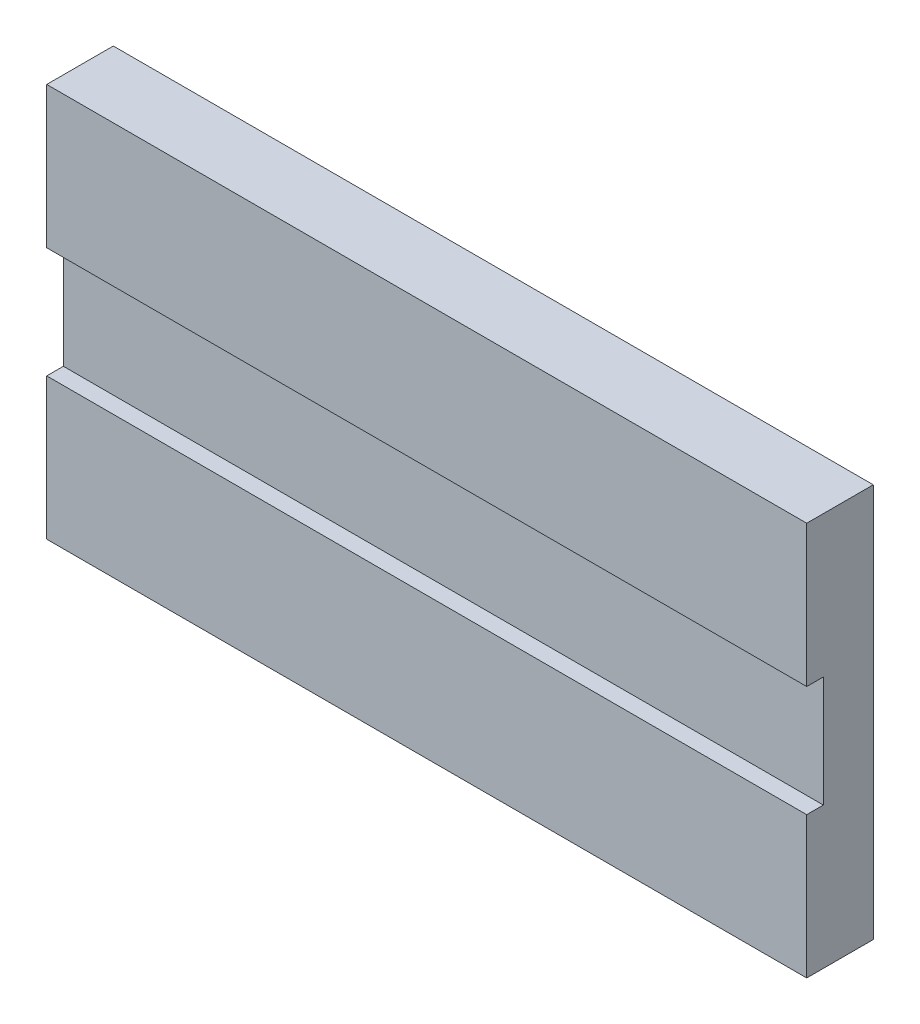
from build123d import *

# Parameters (mm, degrees)
ESQUISSE1_W      = 137
ESQUISSE1_H      = 71
EXTRUSION1_DEPTH = 12
ESQUISSE2_W      = 3
ESQUISSE2_H      = 20
EXTRUSION2_DEPTH = 138


with BuildPart() as part:
    # Esquisse1 → Extrusion1 (new body)
    with BuildSketch(Plane.XY):
        with Locations((68.5, -35.5)):
            Rectangle(ESQUISSE1_W, ESQUISSE1_H)
    extrude(amount=EXTRUSION1_DEPTH)

    # Esquisse2 → Extrusion2 (cut, through all)
    with BuildSketch(Plane(origin=(137, 0, 0), x_dir=(0, 0, -1), z_dir=(1, 0, 0))):
        with Locations((-10.5, -35.5)):
            Rectangle(ESQUISSE2_W, ESQUISSE2_H)
    extrude(amount=-EXTRUSION2_DEPTH, mode=Mode.SUBTRACT)


solid = part.part
